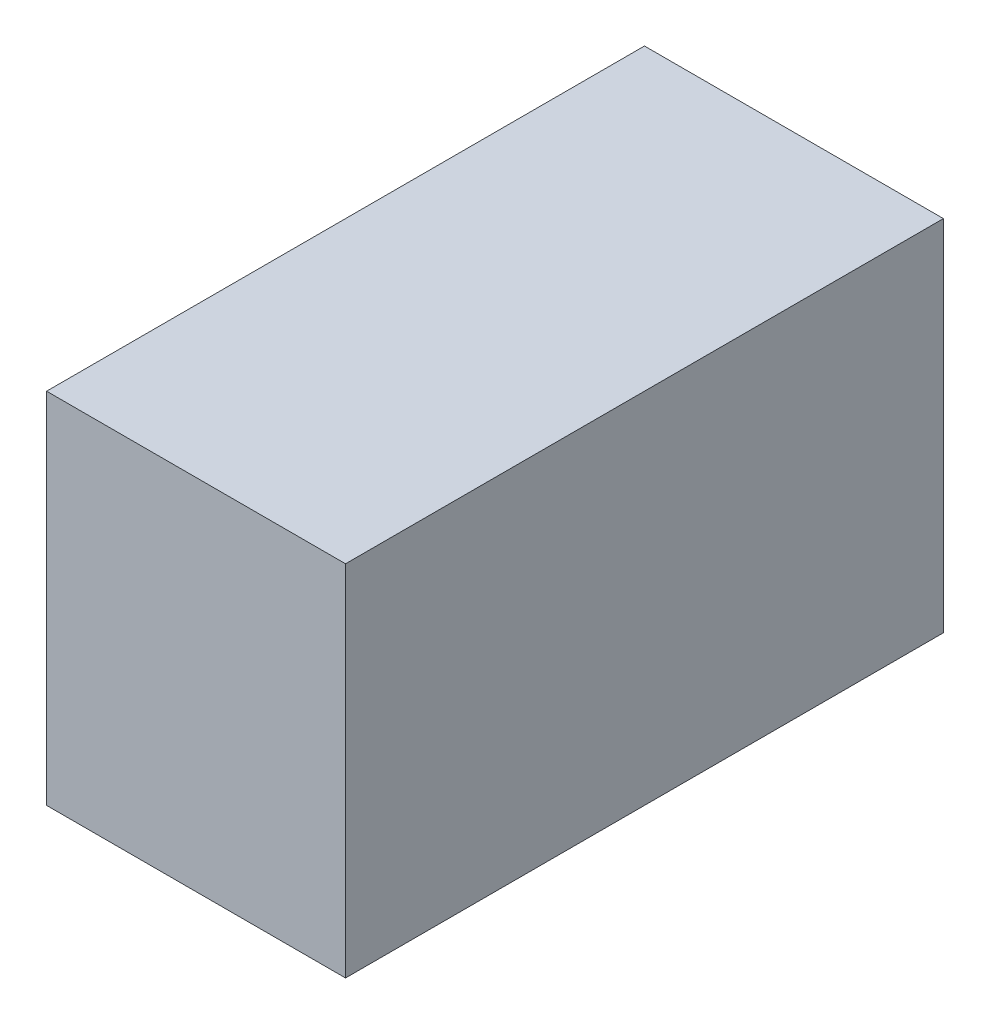
from build123d import *

# Parameters (mm, degrees)
SKETCH1_W           = 6.35
SKETCH1_H           = 3.81
BOSS_EXTRUDE1_DEPTH = 3.175


with BuildPart() as part:
    # Sketch1 → Boss-Extrude1 (new body)
    with BuildSketch(Plane(origin=(0, 0, 0), x_dir=(0, 0, -1), z_dir=(1, 0, 0))):
        with Locations((-6.879166667, 2.504722222)):
            Rectangle(SKETCH1_W, SKETCH1_H)
    extrude(amount=BOSS_EXTRUDE1_DEPTH)


solid = part.part
